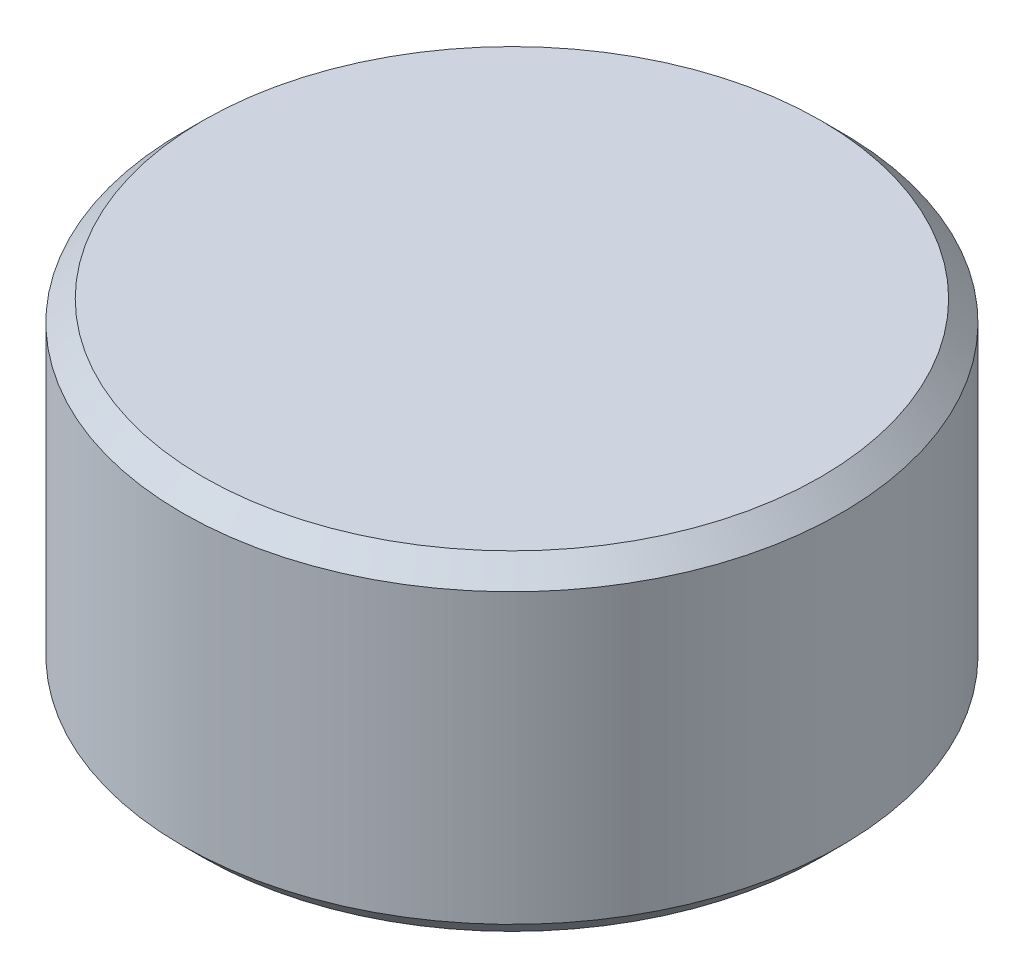
from build123d import *

# Parameters (mm, degrees)
SKETCH1_R           = 1.5875
BOSS_EXTRUDE1_DEPTH = 0.79375
CHAMFER1_SIZE       = 0.1


with BuildPart() as part:
    # Sketch1 → Boss-Extrude1 (new body, symmetric)
    with BuildSketch(Plane(origin=(0, 0, 0), x_dir=(1, 0, 0), z_dir=(0, 1, 0))):
        Circle(SKETCH1_R)
    extrude(amount=BOSS_EXTRUDE1_DEPTH, both=True)

    # Chamfer1
    chamfer1_edges = [part.edges().sort_by_distance(p)[0] for p in [
        (-1.5875, -0.79375, 0),
        (-1.5875, 0.79375, 0),
    ]]
    chamfer(chamfer1_edges, length=CHAMFER1_SIZE)


solid = part.part
